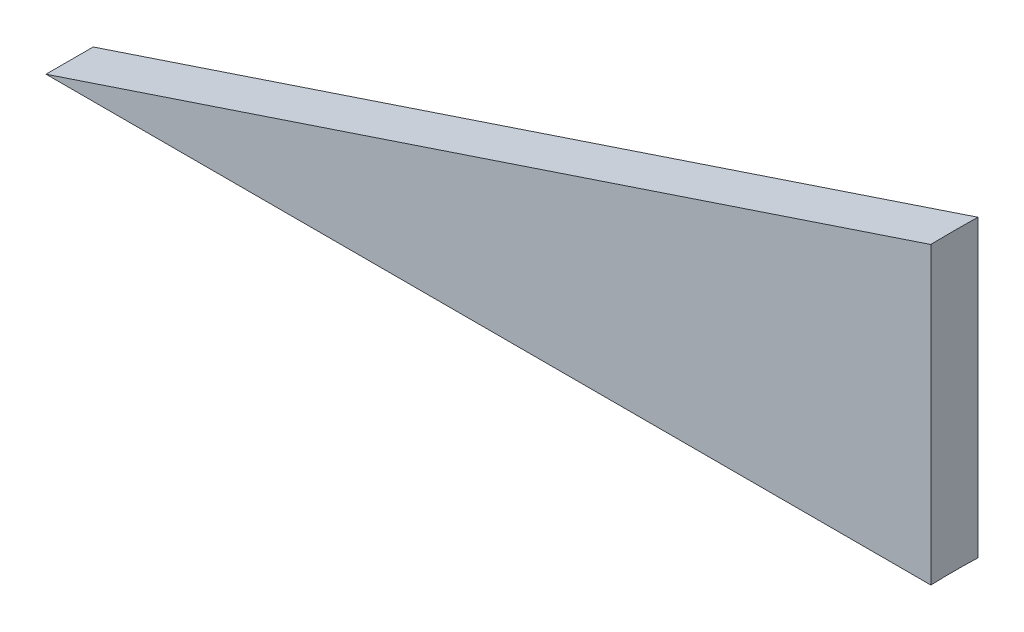
from build123d import *

# Parameters (mm, degrees)
BOSS_EXTRUDE1_DEPTH = 8
SKETCH2_R           = 125
CUT_EXTRUDE1_DEPTH  = 51


with BuildPart() as part:
    # Sketch1 → Boss-Extrude1 (new body)
    with BuildSketch(Plane.XY):
        Polygon((0, 0), (150, 0), (150, 50), align=None)
    extrude(amount=BOSS_EXTRUDE1_DEPTH)

    # Sketch2 → Cut-Extrude1 (cut, through all)
    with BuildSketch(Plane.XZ):
        with Locations((274.935983608, 4)):
            Circle(SKETCH2_R)
    extrude(amount=-CUT_EXTRUDE1_DEPTH, mode=Mode.SUBTRACT)


solid = part.part
